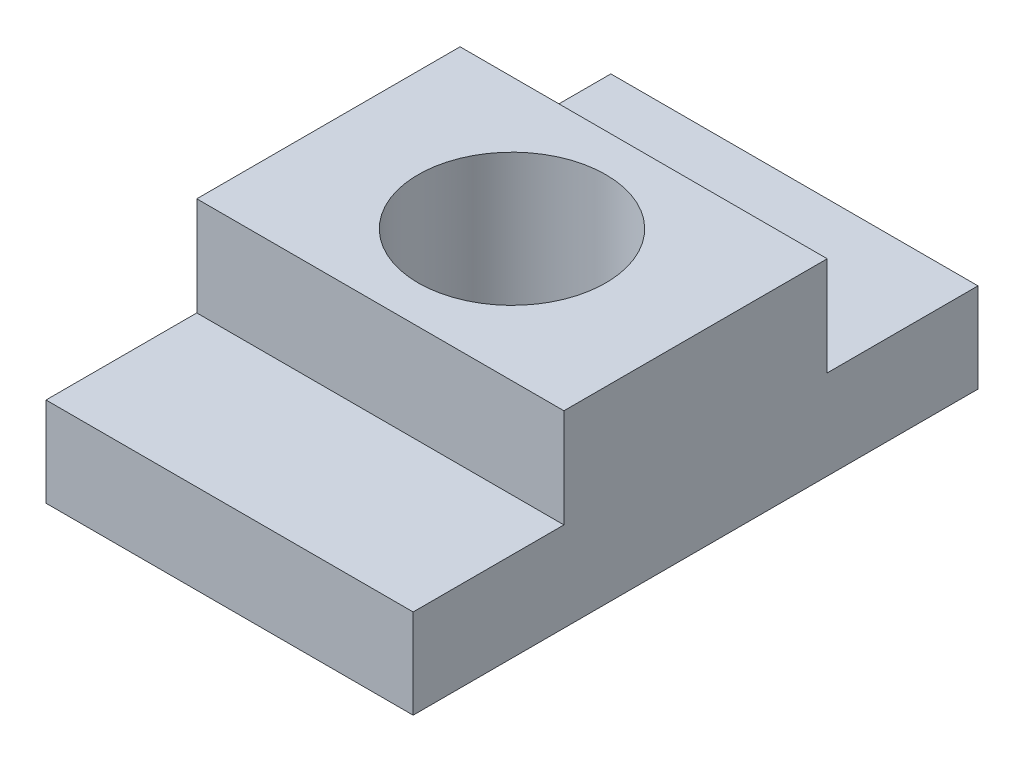
from build123d import *

# Parameters (mm, degrees)
SKETCH1_W           = 30.95625
SKETCH1_H           = 47.625
SKETCH1_R           = 7.9121
BOSS_EXTRUDE1_DEPTH = 7.540625
SKETCH2_W           = 30.95625
SKETCH2_H           = 22.1996
SKETCH2_R           = 7.9121
BOSS_EXTRUDE2_DEPTH = 8.334375


with BuildPart() as part:
    # Sketch1 → Boss-Extrude1 (new body)
    with BuildSketch(Plane(origin=(0, 0, 0), x_dir=(1, 0, 0), z_dir=(0, 1, 0))):
        Rectangle(SKETCH1_W, SKETCH1_H)
        Circle(SKETCH1_R, mode=Mode.SUBTRACT)
    extrude(amount=BOSS_EXTRUDE1_DEPTH)

    # Sketch2 → Boss-Extrude2 (add)
    with BuildSketch(Plane(origin=(0, 7.540625, 0), x_dir=(1, 0, 0), z_dir=(0, 1, 0))):
        Rectangle(SKETCH2_W, SKETCH2_H)
        Circle(SKETCH2_R, mode=Mode.SUBTRACT)
    extrude(amount=BOSS_EXTRUDE2_DEPTH)


solid = part.part
